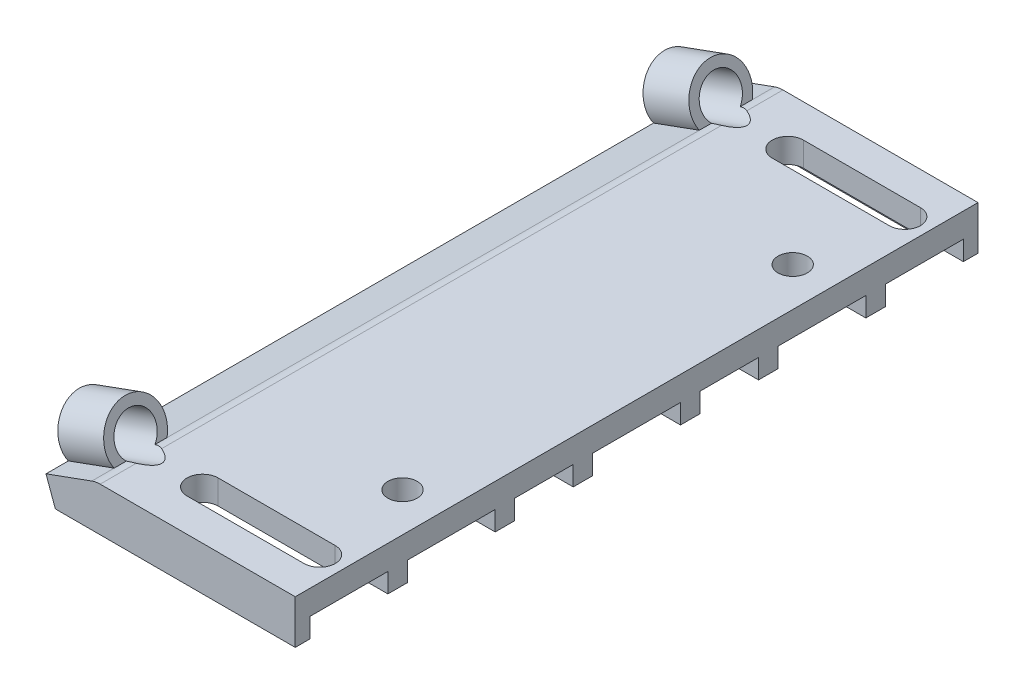
from build123d import *

# Parameters (mm, degrees)
SKETCH_1_W          = 8
SKETCH_1_H          = 70
SKETCH_1_R          = 1.5
EXTRUDE_1_DEPTH     = 2.5
SKETCH_4_W          = 70
SKETCH_4_H          = 2.5
EXTRUDE_3_DEPTH     = 12
EXTRUDE_4_DEPTH     = 70
SKETCH_7_R          = 3.1
SKETCH_7_R_2        = 2.1
EXTRUDE_2_DEPTH     = 5
SKETCH_8_W          = 70
SKETCH_8_H          = 2.5
EXTRUDE_5_DEPTH     = 5
CUT_EXTRUDE_1_REACH = 28.076
SKETCH_9_R          = 2.1
CUT_EXTRUDE_2_DEPTH = 10
EXTRUDE_6_REACH     = 29.127
SKETCH_15_W         = 1.5
SKETCH_15_H         = 2
SKETCH_15_W_2       = 2


with BuildPart() as part:
    # 草图1 → 凸台-拉伸1 (new body)
    with BuildSketch(Plane(origin=(0, 0, 0), x_dir=(1, 0, 0), z_dir=(0, 1, 0))):
        Rectangle(SKETCH_1_W, SKETCH_1_H)
        with Locations((0, 30)):
            Circle(SKETCH_1_R, mode=Mode.SUBTRACT)
        with Locations((0, 20)):
            Circle(SKETCH_1_R, mode=Mode.SUBTRACT)
        with Locations((0, -20)):
            Circle(SKETCH_1_R, mode=Mode.SUBTRACT)
        with Locations((0, -30)):
            Circle(SKETCH_1_R, mode=Mode.SUBTRACT)
    extrude(amount=EXTRUDE_1_DEPTH)

    # 草图4 → 凸台-拉伸3 (add)
    with BuildSketch(Plane.ZY.offset(4)):
        with Locations((0, 1.25)):
            Rectangle(SKETCH_4_W, SKETCH_4_H)
    extrude(amount=EXTRUDE_3_DEPTH)

    # 草图6 → 凸台-拉伸4 (add)
    with BuildSketch(Plane.XY.offset(35)):
        with BuildLine():
            Line((-16.855050358, 2.349231552), (-16, 0))
            Line((-16, 0), (-16, 2.5))
            ThreePointArc((-16, 2.5), (-16.434120444, 2.462019383), (-16.855050358, 2.349231552))
        make_face()
    extrude(amount=-EXTRUDE_4_DEPTH)

    # 草图7 → 拉伸-薄壁2 (add)
    with BuildSketch(Plane(origin=(-14.128355545, -5.142300877, 0), x_dir=(0, 0, 1), z_dir=(-0.939692621, -0.342020143, 0))):
        with Locations((30, 9.472322293)):
            Circle(SKETCH_7_R)
        with Locations((30, 9.472322293)):
            Circle(SKETCH_7_R_2, mode=Mode.SUBTRACT)
        with Locations((-30, 9.472322293)):
            Circle(SKETCH_7_R)
        with Locations((-30, 9.472322293)):
            Circle(SKETCH_7_R_2, mode=Mode.SUBTRACT)
    extrude(amount=EXTRUDE_2_DEPTH)

    # 草图8 → 凸台-拉伸5 (add)
    with BuildSketch(Plane(origin=(-14.128355545, -5.142300877, 0), x_dir=(0, 0, 1), z_dir=(-0.939692621, -0.342020143, 0))):
        with Locations((0, 6.722322293)):
            Rectangle(SKETCH_8_W, SKETCH_8_H)
    extrude(amount=EXTRUDE_5_DEPTH)

    # 草图9 → 切除-拉伸1 (cut, up to next)
    with BuildSketch(Plane(origin=(-18.826818649, -6.852401594, 0), x_dir=(0, 0, 1), z_dir=(-0.939692621, -0.342020143, 0)), mode=Mode.PRIVATE) as cut_extrude_1_sk1:
        with Locations((-30, 9.472322293)):
            Circle(SKETCH_9_R)
    cut_extrude_1_tool1 = extrude(cut_extrude_1_sk1.sketch, amount=-CUT_EXTRUDE_1_REACH, mode=Mode.PRIVATE) & part.part
    add(cut_extrude_1_tool1.solids().sort_by_distance((-22.066544, 2.04867, -30))[0], mode=Mode.SUBTRACT)
    # 草图9 → 切除-拉伸1 (cut, up to next)
    with BuildSketch(Plane(origin=(-18.826818649, -6.852401594, 0), x_dir=(0, 0, 1), z_dir=(-0.939692621, -0.342020143, 0)), mode=Mode.PRIVATE) as cut_extrude_1_sk2:
        with Locations((30, 9.472322293)):
            Circle(SKETCH_9_R)
    cut_extrude_1_tool2 = extrude(cut_extrude_1_sk2.sketch, amount=-CUT_EXTRUDE_1_REACH, mode=Mode.PRIVATE) & part.part
    add(cut_extrude_1_tool2.solids().sort_by_distance((-22.066544, 2.04867, 30))[0], mode=Mode.SUBTRACT)

    # 草图11 → 切除-拉伸2 (cut)
    with BuildSketch(Plane(origin=(0, 2.5, 0), x_dir=(1, 0, 0), z_dir=(0, 1, 0))):
        with BuildLine():
            Line((1.500000061, 28.40000046), (-10.499999939, 28.4))
            ThreePointArc((-10.499999939, 28.4), (-12.1, 29.999999939), (-10.500000061, 31.6))
            Line((-10.500000061, 31.6), (1.499999939, 31.60000046))
            ThreePointArc((1.499999939, 31.60000046), (3.1, 30.000000521), (1.500000061, 28.40000046))
        make_face()
        with BuildLine():
            Line((1.500000061, -31.59999977), (-10.499999939, -31.60000023))
            ThreePointArc((-10.499999939, -31.60000023), (-12.1, -30.000000291), (-10.500000061, -28.40000023))
            Line((-10.500000061, -28.40000023), (1.499999939, -28.39999977))
            ThreePointArc((1.499999939, -28.39999977), (3.1, -29.999999709), (1.500000061, -31.59999977))
        make_face()
    extrude(amount=-CUT_EXTRUDE_2_DEPTH, mode=Mode.SUBTRACT)

    # 凸台-拉伸6: up to this face of the body (flat: up to its plane)
    extrude_6_end = Plane(part.part.faces().sort_by_distance((-21.270490347, -0.138468784, 0))[0])
    # 草图15 → 凸台-拉伸6 (add, up to the picked face)
    with BuildSketch(Plane(origin=(4, 0, 0), x_dir=(0, 0, -1), z_dir=(1, 0, 0)), mode=Mode.PRIVATE) as extrude_6_sk1:
        with Locations((-34.25, -1)):
            Rectangle(SKETCH_15_W, SKETCH_15_H)
    extrude_6_tool1 = split(extrude(extrude_6_sk1.sketch, amount=-EXTRUDE_6_REACH, mode=Mode.PRIVATE), bisect_by=extrude_6_end, keep=Keep.BOTH, mode=Mode.PRIVATE)
    add(extrude_6_tool1.solids().sort_by_distance((4, -1, 34.25))[0])
    # 草图15 → 凸台-拉伸6 (add, up to the picked face)
    with BuildSketch(Plane(origin=(4, 0, 0), x_dir=(0, 0, -1), z_dir=(1, 0, 0)), mode=Mode.PRIVATE) as extrude_6_sk2:
        with Locations((-24.5, -1)):
            Rectangle(SKETCH_15_W_2, SKETCH_15_H)
    extrude_6_tool2 = split(extrude(extrude_6_sk2.sketch, amount=-EXTRUDE_6_REACH, mode=Mode.PRIVATE), bisect_by=extrude_6_end, keep=Keep.BOTH, mode=Mode.PRIVATE)
    add(extrude_6_tool2.solids().sort_by_distance((4, -1, 24.5))[0])
    # 草图15 → 凸台-拉伸6 (add, up to the picked face)
    with BuildSketch(Plane(origin=(4, 0, 0), x_dir=(0, 0, -1), z_dir=(1, 0, 0)), mode=Mode.PRIVATE) as extrude_6_sk3:
        with Locations((-13.5, -1)):
            Rectangle(SKETCH_15_W_2, SKETCH_15_H)
    extrude_6_tool3 = split(extrude(extrude_6_sk3.sketch, amount=-EXTRUDE_6_REACH, mode=Mode.PRIVATE), bisect_by=extrude_6_end, keep=Keep.BOTH, mode=Mode.PRIVATE)
    add(extrude_6_tool3.solids().sort_by_distance((4, -1, 13.5))[0])
    # 草图15 → 凸台-拉伸6 (add, up to the picked face)
    with BuildSketch(Plane(origin=(4, 0, 0), x_dir=(0, 0, -1), z_dir=(1, 0, 0)), mode=Mode.PRIVATE) as extrude_6_sk4:
        with Locations((-5.5, -1)):
            Rectangle(SKETCH_15_W_2, SKETCH_15_H)
    extrude_6_tool4 = split(extrude(extrude_6_sk4.sketch, amount=-EXTRUDE_6_REACH, mode=Mode.PRIVATE), bisect_by=extrude_6_end, keep=Keep.BOTH, mode=Mode.PRIVATE)
    add(extrude_6_tool4.solids().sort_by_distance((4, -1, 5.5))[0])
    # 草图15 → 凸台-拉伸6 (add, up to the picked face)
    with BuildSketch(Plane(origin=(4, 0, 0), x_dir=(0, 0, -1), z_dir=(1, 0, 0)), mode=Mode.PRIVATE) as extrude_6_sk5:
        with Locations((5.5, -1)):
            Rectangle(SKETCH_15_W_2, SKETCH_15_H)
    extrude_6_tool5 = split(extrude(extrude_6_sk5.sketch, amount=-EXTRUDE_6_REACH, mode=Mode.PRIVATE), bisect_by=extrude_6_end, keep=Keep.BOTH, mode=Mode.PRIVATE)
    add(extrude_6_tool5.solids().sort_by_distance((4, -1, -5.5))[0])
    # 草图15 → 凸台-拉伸6 (add, up to the picked face)
    with BuildSketch(Plane(origin=(4, 0, 0), x_dir=(0, 0, -1), z_dir=(1, 0, 0)), mode=Mode.PRIVATE) as extrude_6_sk6:
        with Locations((13.5, -1)):
            Rectangle(SKETCH_15_W_2, SKETCH_15_H)
    extrude_6_tool6 = split(extrude(extrude_6_sk6.sketch, amount=-EXTRUDE_6_REACH, mode=Mode.PRIVATE), bisect_by=extrude_6_end, keep=Keep.BOTH, mode=Mode.PRIVATE)
    add(extrude_6_tool6.solids().sort_by_distance((4, -1, -13.5))[0])
    # 草图15 → 凸台-拉伸6 (add, up to the picked face)
    with BuildSketch(Plane(origin=(4, 0, 0), x_dir=(0, 0, -1), z_dir=(1, 0, 0)), mode=Mode.PRIVATE) as extrude_6_sk7:
        with Locations((34.25, -1)):
            Rectangle(SKETCH_15_W, SKETCH_15_H)
    extrude_6_tool7 = split(extrude(extrude_6_sk7.sketch, amount=-EXTRUDE_6_REACH, mode=Mode.PRIVATE), bisect_by=extrude_6_end, keep=Keep.BOTH, mode=Mode.PRIVATE)
    add(extrude_6_tool7.solids().sort_by_distance((4, -1, -34.25))[0])
    # 草图15 → 凸台-拉伸6 (add, up to the picked face)
    with BuildSketch(Plane(origin=(4, 0, 0), x_dir=(0, 0, -1), z_dir=(1, 0, 0)), mode=Mode.PRIVATE) as extrude_6_sk8:
        with Locations((24.5, -1)):
            Rectangle(SKETCH_15_W_2, SKETCH_15_H)
    extrude_6_tool8 = split(extrude(extrude_6_sk8.sketch, amount=-EXTRUDE_6_REACH, mode=Mode.PRIVATE), bisect_by=extrude_6_end, keep=Keep.BOTH, mode=Mode.PRIVATE)
    add(extrude_6_tool8.solids().sort_by_distance((4, -1, -24.5))[0])


solid = part.part
